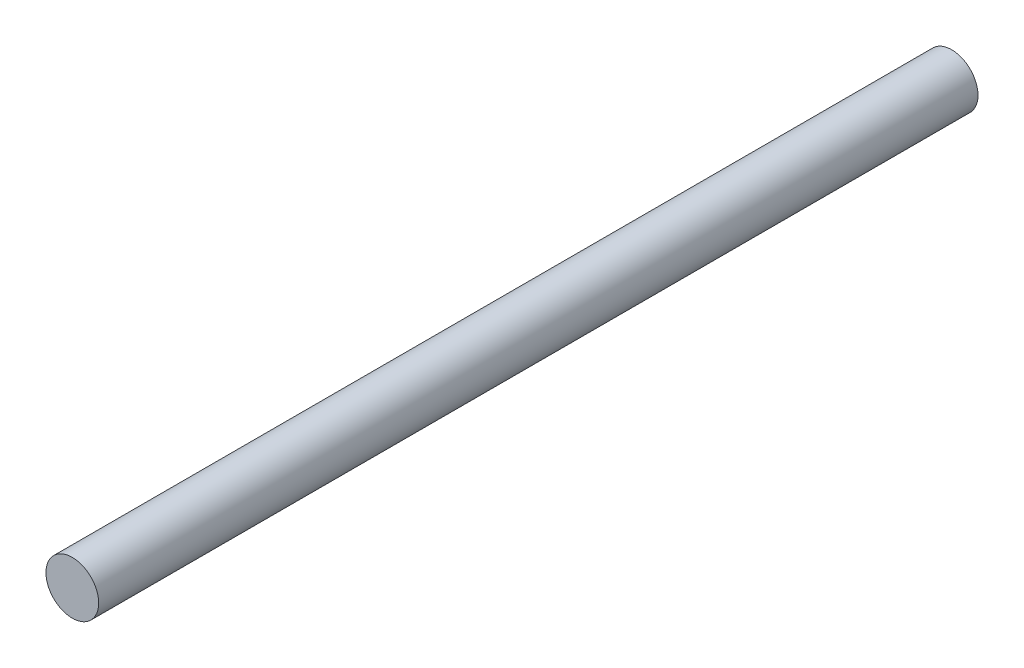
from build123d import *

# Parameters (mm, degrees)
SKETCH1_R           = 2.998
BOSS_EXTRUDE1_DEPTH = 100


with BuildPart() as part:
    # Sketch1 → Boss-Extrude1 (new body)
    with BuildSketch(Plane.XY):
        Circle(SKETCH1_R)
    extrude(amount=BOSS_EXTRUDE1_DEPTH)


solid = part.part
